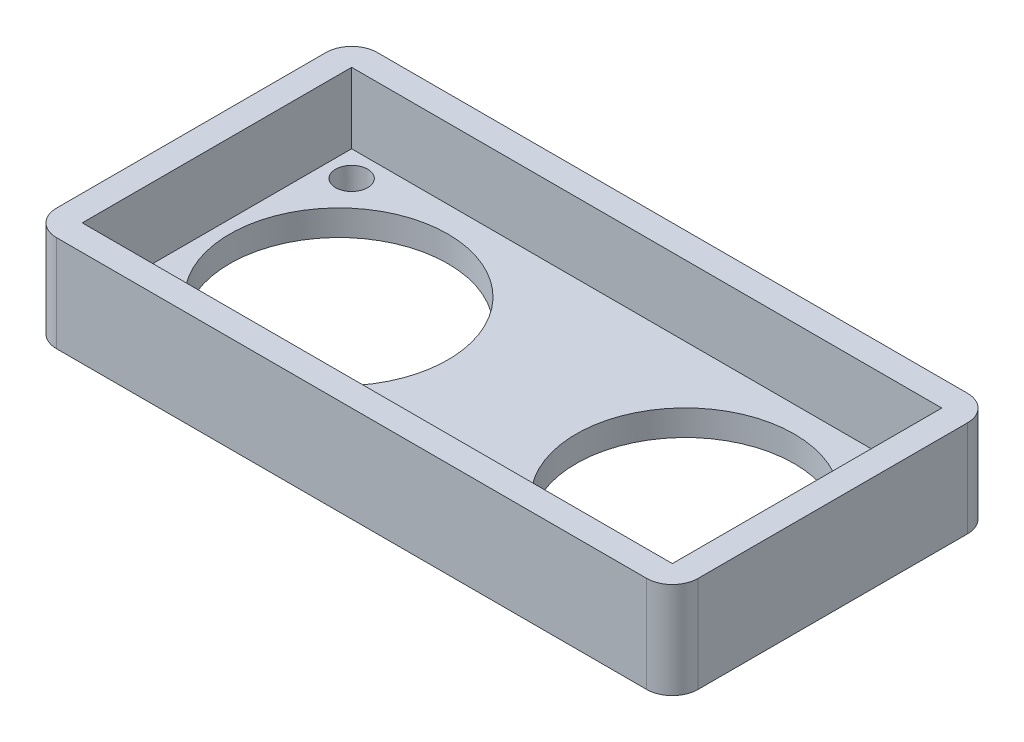
from build123d import *

# Parameters (mm, degrees)
EXTRUDE_1_DEPTH     = 2
SKETCH_2_W          = 46
SKETCH_2_H          = 21
EXTRUDE_2_DEPTH     = 5.5
SKETCH_3_R          = 1.25
CUT_EXTRUDE_1_DEPTH = 8.5
SKETCH_4_R          = 8.5
CUT_EXTRUDE_2_DEPTH = 8.5


with BuildPart() as part:
    # 草图1 → 凸台-拉伸1 (new body)
    with BuildSketch(Plane(origin=(0, 0, 0), x_dir=(1, 0, 0), z_dir=(0, 1, 0))):
        with BuildLine():
            Line((-23, 12.5), (23, 12.5))
            ThreePointArc((23, 12.5), (24.414213562, 11.914213562), (25, 10.5))
            Line((25, 10.5), (25, -10.5))
            ThreePointArc((25, -10.5), (24.414213562, -11.914213562), (23, -12.5))
            Line((23, -12.5), (-23, -12.5))
            ThreePointArc((-23, -12.5), (-24.414213562, -11.914213562), (-25, -10.5))
            Line((-25, -10.5), (-25, 10.5))
            ThreePointArc((-25, 10.5), (-24.414213562, 11.914213562), (-23, 12.5))
        make_face()
    extrude(amount=EXTRUDE_1_DEPTH)

    # 草图2 → 凸台-拉伸2 (add)
    with BuildSketch(Plane(origin=(0, 2, 0), x_dir=(1, 0, 0), z_dir=(0, 1, 0))):
        with BuildLine():
            Line((23, 12.5), (-23, 12.5))
            ThreePointArc((-23, 12.5), (-24.414213562, 11.914213562), (-25, 10.5))
            Line((-25, 10.5), (-25, -10.5))
            ThreePointArc((-25, -10.5), (-24.414213562, -11.914213562), (-23, -12.5))
            Line((-23, -12.5), (23, -12.5))
            ThreePointArc((23, -12.5), (24.414213562, -11.914213562), (25, -10.5))
            Line((25, -10.5), (25, 10.5))
            ThreePointArc((25, 10.5), (24.414213562, 11.914213562), (23, 12.5))
        make_face()
        Rectangle(SKETCH_2_W, SKETCH_2_H, mode=Mode.SUBTRACT)
    extrude(amount=EXTRUDE_2_DEPTH)

    # 草图3 → 切除-拉伸1 (cut, through all)
    with BuildSketch(Plane.XZ):
        with Locations((-21, 8.5)):
            Circle(SKETCH_3_R)
        with Locations((-21, -8.5)):
            Circle(SKETCH_3_R)
        with Locations((21, 8.5)):
            Circle(SKETCH_3_R)
        with Locations((21, -8.5)):
            Circle(SKETCH_3_R)
    extrude(amount=-CUT_EXTRUDE_1_DEPTH, mode=Mode.SUBTRACT)

    # 草图4 → 切除-拉伸2 (cut, through all)
    with BuildSketch(Plane.XZ):
        with Locations((-13.5, 0)):
            Circle(SKETCH_4_R)
        with Locations((13.5, 0)):
            Circle(SKETCH_4_R)
    extrude(amount=-CUT_EXTRUDE_2_DEPTH, mode=Mode.SUBTRACT)


solid = part.part
